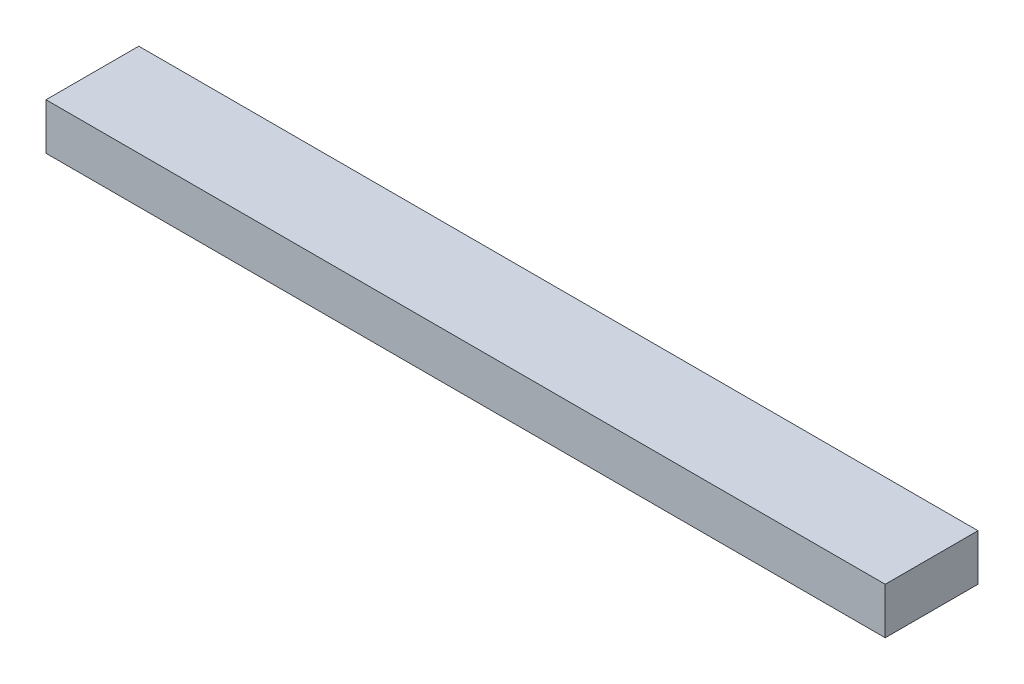
from build123d import *

# Parameters (mm, degrees)
SKETCH_1_W      = 200
SKETCH_1_H      = 100
EXTRUDE_1_DEPTH = 1809


with BuildPart() as part:
    # 草图1 → 凸台-拉伸1 (new body)
    with BuildSketch(Plane(origin=(0, 0, 0), x_dir=(0, 0, -1), z_dir=(1, 0, 0))):
        Rectangle(SKETCH_1_W, SKETCH_1_H)
    extrude(amount=-EXTRUDE_1_DEPTH)


solid = part.part
